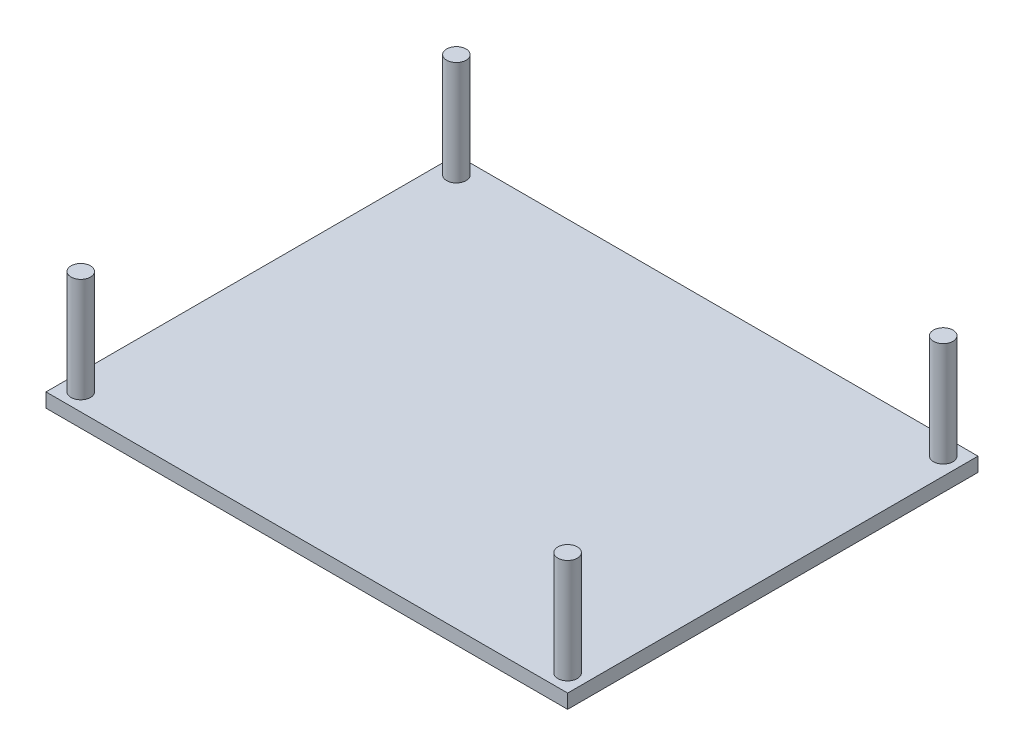
from build123d import *

# Parameters (mm, degrees)
SKETCH1_W           = 75
SKETCH1_H           = 59
BOSS_EXTRUDE1_DEPTH = 2.032
SKETCH2_R           = 1.399999994
SKETCH2_R_2         = 1.4
BOSS_EXTRUDE2_DEPTH = 15


with BuildPart() as part:
    # Sketch1 → Boss-Extrude1 (new body)
    with BuildSketch(Plane(origin=(0, 0, 0), x_dir=(1, 0, 0), z_dir=(0, 1, 0))):
        with Locations((37.5, 29.5)):
            Rectangle(SKETCH1_W, SKETCH1_H)
    extrude(amount=-BOSS_EXTRUDE1_DEPTH)

    # Sketch2 → Boss-Extrude2 (add)
    with BuildSketch(Plane(origin=(0, 0, 0), x_dir=(1, 0, 0), z_dir=(0, 1, 0))):
        with Locations((2.5, 2.5)):
            Circle(SKETCH2_R)
        with Locations((72.5, 2.5)):
            Circle(SKETCH2_R_2)
        with Locations((72.5, 56.5)):
            Circle(SKETCH2_R_2)
        with Locations((2.5, 56.5)):
            Circle(SKETCH2_R)
    extrude(amount=BOSS_EXTRUDE2_DEPTH)


solid = part.part
